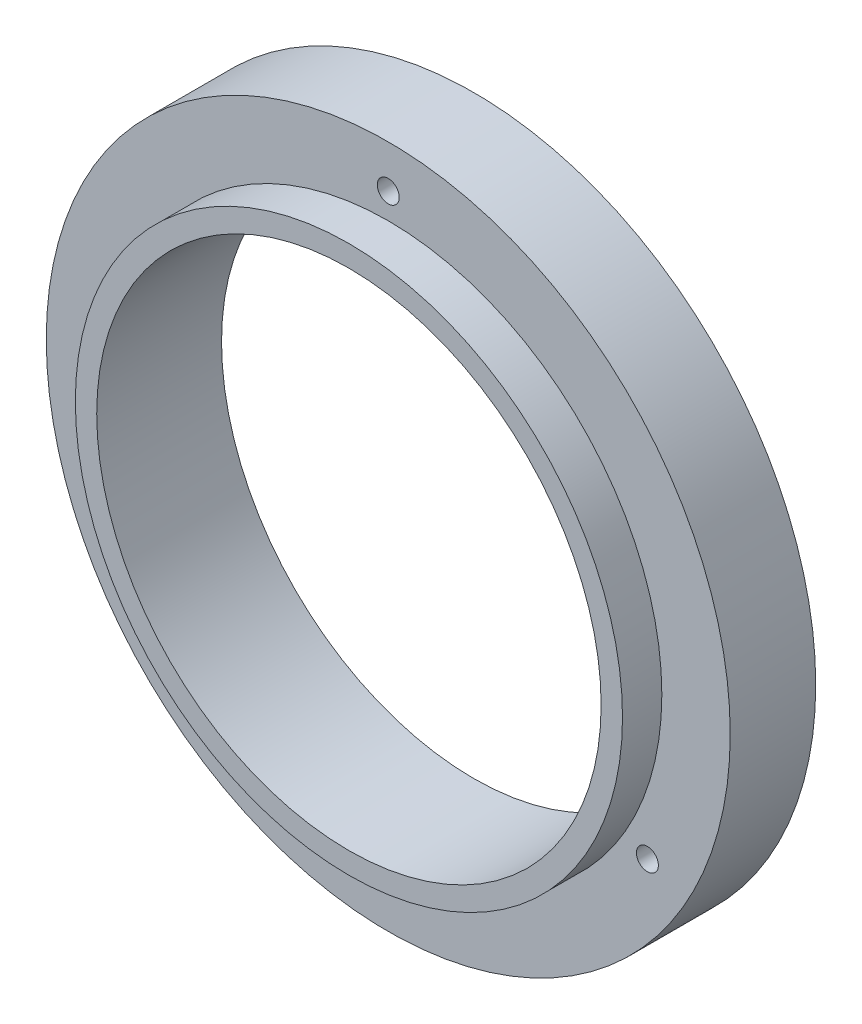
from build123d import *

# Parameters (mm, degrees)
SKETCH1_R           = 50.8
BOSS_EXTRUDE1_DEPTH = 12.7
SKETCH2_R           = 40.64
SKETCH2_R_2         = 37.465
BOSS_EXTRUDE2_DEPTH = 5.842
SKETCH4_R           = 37.465
CUT_EXTRUDE1_DEPTH  = 13.7
CIRPATTERN1_COUNT   = 3


with BuildPart() as part:
    # Sketch1 → Boss-Extrude1 (new body)
    with BuildSketch(Plane.XY):
        Circle(SKETCH1_R)
    extrude(amount=BOSS_EXTRUDE1_DEPTH)

    # Sketch2 → Boss-Extrude2 (add)
    with BuildSketch(Plane.XY.offset(12.7)):
        Circle(SKETCH2_R)
        Circle(SKETCH2_R_2, mode=Mode.SUBTRACT)
    extrude(amount=BOSS_EXTRUDE2_DEPTH)

    # Sketch4 → Cut-Extrude1 (cut, through all)
    with BuildSketch(Plane.XY.offset(12.7)):
        Circle(SKETCH4_R)
    extrude(amount=-CUT_EXTRUDE1_DEPTH, mode=Mode.SUBTRACT)

    # Sketch6 → CBORE for #4 Socket Head Cap Screw1 (revolve, cut)
    with BuildSketch(Plane(origin=(0, 44.45, 0), x_dir=(0, 1, 0), z_dir=(1, 0, 0))):
        Polygon((0, 0), (0, 13.807574487), (1.63195, 12.827), (1.63195, 2.8448), (2.77876, 2.8448), (2.77876, 0), align=None)
    cbore_for_4_socket_head_cap_screw1 = revolve(axis=Axis((0, 44.45, -6.35), (0, 0, 1)), mode=Mode.SUBTRACT)

    # CirPattern1: CBORE for #4 Socket Head Cap Screw1 ×3 about axis
    cirpattern1_axis = Axis((0, 0, 0), (0, 0, 1))
    for i in range(1, CIRPATTERN1_COUNT):
        add(cbore_for_4_socket_head_cap_screw1.rotate(cirpattern1_axis, i * 360 / CIRPATTERN1_COUNT), mode=Mode.SUBTRACT)


solid = part.part
